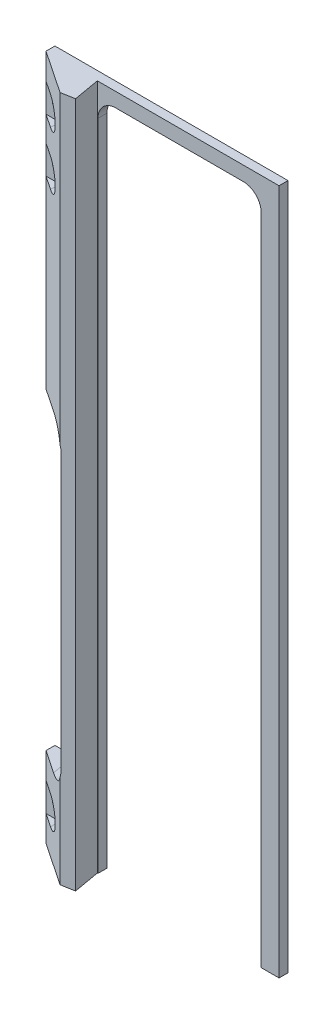
from build123d import *

# Parameters (mm, degrees)
SKETCH2_W                  = 82.738044028
SKETCH2_H                  = 243.598411898
BOSS_EXTRUDE1_DEPTH        = 3.175
BOSS_EXTRUDE2_DEPTH        = 243.598412
SKETCH3_W                  = 13.462
SKETCH3_H                  = 111.125
CUT_EXTRUDE1_DEPTH         = 16.816415828
CUT_EXTRUDE1_DEPTH_BACK    = 12.72988093
FILLET1_R                  = 6.35
SKETCH4_W                  = 57.955870979
SKETCH4_H                  = 238.518411898
CUT_EXTRUDE2_DEPTH         = 4.175
FILLET2_R                  = 6.35
F_6_0_204_DIAMETER_HOLE1_D = 5.1816
CUT_EXTRUDE3_DEPTH         = 11.207293294


with BuildPart() as part:
    # Sketch2 → Boss-Extrude1 (new body)
    with BuildSketch(Plane.XY):
        with Locations((870.137648104, 6053.851709568)):
            Rectangle(SKETCH2_W, SKETCH2_H)
    extrude(amount=BOSS_EXTRUDE1_DEPTH)

    # Sketch5 → Boss-Extrude2 (add, through all)
    with BuildSketch(Plane(origin=(0, 6175.650915517, 0), x_dir=(1, 0, 0), z_dir=(0, 1, 0))):
        Polygon((828.76862609, -3.175), (843.956978058, -13.382293294), (848.647124982, -12.555293847), (846.99312609, -3.175), align=None)
    extrude(amount=-BOSS_EXTRUDE2_DEPTH)

    # Sketch3 → Cut-Extrude1 (cut, two sides)
    with BuildSketch(Plane(origin=(1789.989771594, 0, -153.428812844), x_dir=(-0.984807753, 0, 0.173648178), z_dir=(-0.173648178, 0, -0.984807753))) as cut_extrude1_sk:
        with Locations((967.081003168, 6016.190003619)):
            Rectangle(SKETCH3_W, SKETCH3_H)
    extrude(amount=CUT_EXTRUDE1_DEPTH, mode=Mode.SUBTRACT)
    extrude(cut_extrude1_sk.sketch, amount=-CUT_EXTRUDE1_DEPTH_BACK, mode=Mode.SUBTRACT)

    # Fillet1
    fillet1_edges = [part.edges().sort_by_distance(p)[0] for p in [
        (843.054051922, 6071.752503619, 6.667107565),
        (843.054051922, 5960.627503619, 6.667107565),
    ]]
    fillet(fillet1_edges, radius=FILLET1_R)

    # Sketch4 → Cut-Extrude2 (cut, through all)
    with BuildSketch(Plane.XY.offset(3.175)):
        with Locations((876.178734629, 6051.311709568)):
            Rectangle(SKETCH4_W, SKETCH4_H)
    extrude(amount=-CUT_EXTRUDE2_DEPTH, mode=Mode.SUBTRACT)

    # Fillet2
    fillet2_edges = [part.edges().sort_by_distance(p)[0] for p in [
        (905.156670118, 6170.570915517, 1.5875),
        (847.200799139, 6170.570915517, 1.5875),
    ]]
    fillet(fillet2_edges, radius=FILLET2_R)

    # #6 (0.204) Diameter Hole1 (through all)
    with Locations(Plane(origin=(0, 0, 0), x_dir=(-1, 0, 0), z_dir=(0, 0, -1))):
        with Locations((-833.65812609, 6161.363415517), (-833.65812609, 6142.313415517), (-833.65812609, 5946.340003619)):
            Hole(F_6_0_204_DIAMETER_HOLE1_D / 2)

    # Sketch8 → Cut-Extrude3 (cut, through all)
    with BuildSketch(Plane.XY.offset(3.175)):
        with BuildLine():
            Line((833.65812609, 6156.283415517), (828.76862609, 6156.283415517))
            ThreePointArc((828.76862609, 6156.283415517), (823.68862609, 6161.363415517), (828.76862609, 6166.443415517))
            Line((828.76862609, 6166.443415517), (833.65812609, 6166.443415517))
            ThreePointArc((833.65812609, 6166.443415517), (838.73812609, 6161.363415517), (833.65812609, 6156.283415517))
        make_face()
        with BuildLine():
            Line((833.65812609, 6137.233415517), (828.76862609, 6137.233415517))
            ThreePointArc((828.76862609, 6137.233415517), (823.68862609, 6142.313415517), (828.76862609, 6147.393415517))
            Line((828.76862609, 6147.393415517), (833.65812609, 6147.393415517))
            ThreePointArc((833.65812609, 6147.393415517), (838.73812609, 6142.313415517), (833.65812609, 6137.233415517))
        make_face()
        with BuildLine():
            Line((833.65812609, 5941.260003619), (828.76862609, 5941.260003619))
            ThreePointArc((828.76862609, 5941.260003619), (823.68862609, 5946.340003619), (828.76862609, 5951.420003619))
            Line((828.76862609, 5951.420003619), (833.65812609, 5951.420003619))
            ThreePointArc((833.65812609, 5951.420003619), (838.73812609, 5946.340003619), (833.65812609, 5941.260003619))
        make_face()
    extrude(amount=CUT_EXTRUDE3_DEPTH, mode=Mode.SUBTRACT)


solid = part.part
